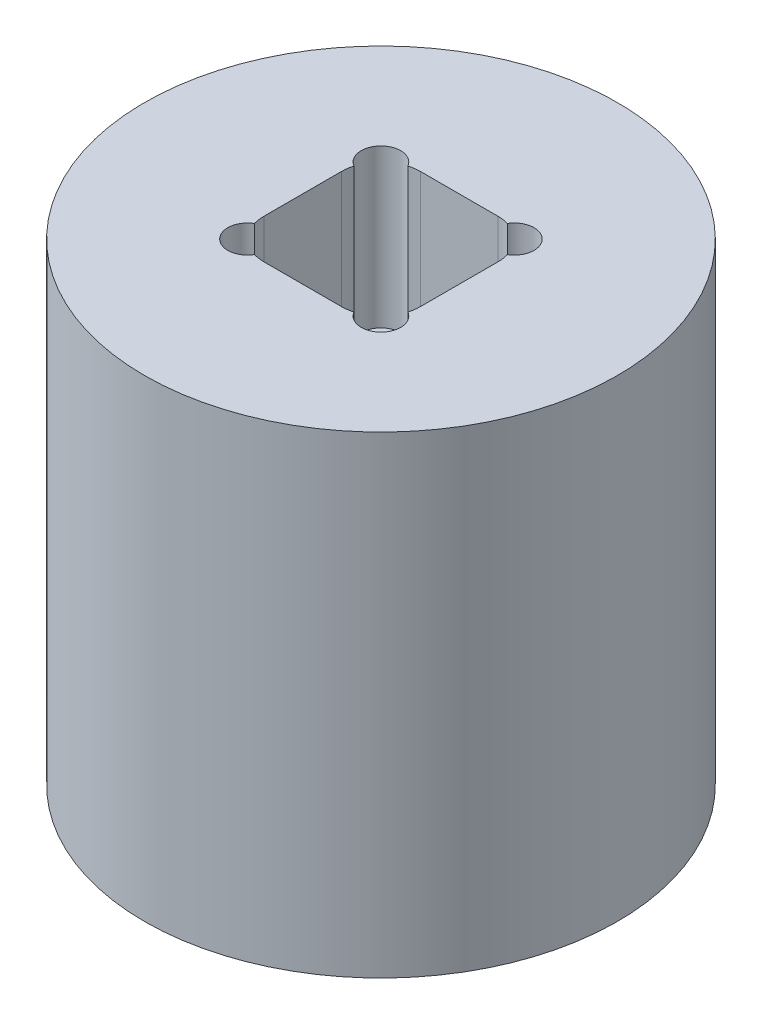
from build123d import *

# Parameters (mm, degrees)
SKETCH1_R           = 19.05
BOSS_EXTRUDE1_DEPTH = 19.05
SKETCH2_W           = 12.6111
SKETCH2_H           = 12.6111
CUT_EXTRUDE1_DEPTH  = 12.7
CUT_EXTRUDE2_DEPTH  = 19.05
FILLET1_R           = 3.175
CUT_EXTRUDE3_DEPTH  = 12.7


with BuildPart() as part:
    # Sketch1 → Boss-Extrude1 (new body, symmetric)
    with BuildSketch(Plane(origin=(0, 0, 0), x_dir=(1, 0, 0), z_dir=(0, 1, 0))):
        Circle(SKETCH1_R)
    extrude(amount=BOSS_EXTRUDE1_DEPTH, both=True)

    # Sketch2 → Cut-Extrude1 (cut)
    with BuildSketch(Plane(origin=(0, 19.05, 0), x_dir=(1, 0, 0), z_dir=(0, 1, 0))):
        Rectangle(SKETCH2_W, SKETCH2_H)
    extrude(amount=-CUT_EXTRUDE1_DEPTH, mode=Mode.SUBTRACT)

    # Sketch3 → Cut-Extrude2 (cut)
    with BuildSketch(Plane.XZ.offset(19.05)):
        with BuildLine():
            Line((9.12495, 12.29995), (-9.12495, 12.29995))
            ThreePointArc((-9.12495, 12.29995), (-11.37001403, 11.37001403), (-12.29995, 9.12495))
            Line((-12.29995, 9.12495), (-12.29995, -9.12495))
            ThreePointArc((-12.29995, -9.12495), (-11.37001403, -11.37001403), (-9.12495, -12.29995))
            Line((-9.12495, -12.29995), (9.12495, -12.29995))
            ThreePointArc((9.12495, -12.29995), (11.37001403, -11.37001403), (12.29995, -9.12495))
            Line((12.29995, -9.12495), (12.29995, 9.12495))
            ThreePointArc((12.29995, 9.12495), (11.37001403, 11.37001403), (9.12495, 12.29995))
        make_face()
    extrude(amount=-CUT_EXTRUDE2_DEPTH, mode=Mode.SUBTRACT)

    # Fillet1
    fillet1_edges = [part.edges().sort_by_distance(p)[0] for p in [
        (-6.30555, 12.7, 6.30555),
        (-6.30555, 12.7, -6.30555),
        (6.30555, 12.7, -6.30555),
        (6.30555, 12.7, 6.30555),
    ]]
    fillet(fillet1_edges, radius=FILLET1_R)

    # Sketch4 → Cut-Extrude3 (cut)
    with BuildSketch(Plane(origin=(0, 19.05, 0), x_dir=(1, 0, 0), z_dir=(0, 1, 0))):
        with BuildLine():
            ThreePointArc((4.008094076, 6.181867977), (4.253082015, 4.253082015), (6.181867977, 4.008094076))
            ThreePointArc((6.181867977, 4.008094076), (5.37561403, 5.37561403), (4.008094076, 6.181867977))
        make_face()
        with BuildLine():
            ThreePointArc((6.181867977, 4.008094076), (6.244651028, 4.047106994), (6.30555, 4.089000125))
            Line((6.30555, 4.089000125), (6.30555, 6.30555))
            Line((6.30555, 6.30555), (4.089000125, 6.30555))
            ThreePointArc((4.089000125, 6.30555), (4.047106994, 6.244651028), (4.008094076, 6.181867977))
            ThreePointArc((4.008094076, 6.181867977), (5.37561403, 5.37561403), (6.181867977, 4.008094076))
        make_face()
        with BuildLine():
            Line((6.30555, 6.30555), (6.30555, 4.089000125))
            ThreePointArc((6.30555, 4.089000125), (6.789196289, 4.653158877), (6.96311403, 5.37561403))
            ThreePointArc((6.96311403, 5.37561403), (5.864314693, 6.886020569), (4.089000125, 6.30555))
            Line((4.089000125, 6.30555), (6.30555, 6.30555))
        make_face()
        with BuildLine():
            ThreePointArc((-4.008094076, 6.181867977), (-5.37561403, 5.37561403), (-6.181867977, 4.008094076))
            ThreePointArc((-6.181867977, 4.008094076), (-4.588140821, 3.997193849), (-3.78811403, 5.37561403))
            ThreePointArc((-3.78811403, 5.37561403), (-3.844096127, 5.793476641), (-4.008094076, 6.181867977))
        make_face()
        with BuildLine():
            Line((-6.30555, 6.30555), (-6.30555, 4.089000125))
            ThreePointArc((-6.30555, 4.089000125), (-6.244651028, 4.047106994), (-6.181867977, 4.008094076))
            ThreePointArc((-6.181867977, 4.008094076), (-5.37561403, 5.37561403), (-4.008094076, 6.181867977))
            ThreePointArc((-4.008094076, 6.181867977), (-4.047106994, 6.244651028), (-4.089000125, 6.30555))
            Line((-4.089000125, 6.30555), (-6.30555, 6.30555))
        make_face()
        with BuildLine():
            ThreePointArc((-4.089000125, 6.30555), (-6.498146045, 6.498146045), (-6.30555, 4.089000125))
            Line((-6.30555, 4.089000125), (-6.30555, 6.30555))
            Line((-6.30555, 6.30555), (-4.089000125, 6.30555))
        make_face()
        with BuildLine():
            ThreePointArc((-6.30555, -4.089000125), (-6.498146045, -6.498146045), (-4.089000125, -6.30555))
            Line((-4.089000125, -6.30555), (-6.30555, -6.30555))
            Line((-6.30555, -6.30555), (-6.30555, -4.089000125))
        make_face()
        with BuildLine():
            Line((-6.30555, -6.30555), (-4.089000125, -6.30555))
            ThreePointArc((-4.089000125, -6.30555), (-4.047106994, -6.244651028), (-4.008094076, -6.181867977))
            ThreePointArc((-4.008094076, -6.181867977), (-5.37561403, -5.37561403), (-6.181867977, -4.008094076))
            ThreePointArc((-6.181867977, -4.008094076), (-6.244651028, -4.047106994), (-6.30555, -4.089000125))
            Line((-6.30555, -4.089000125), (-6.30555, -6.30555))
        make_face()
        with BuildLine():
            ThreePointArc((-6.181867977, -4.008094076), (-5.37561403, -5.37561403), (-4.008094076, -6.181867977))
            ThreePointArc((-4.008094076, -6.181867977), (-3.844096127, -5.793476641), (-3.78811403, -5.37561403))
            ThreePointArc((-3.78811403, -5.37561403), (-4.588140821, -3.997193849), (-6.181867977, -4.008094076))
        make_face()
        with BuildLine():
            ThreePointArc((6.181867977, -4.008094076), (4.253082015, -4.253082015), (4.008094076, -6.181867977))
            ThreePointArc((4.008094076, -6.181867977), (5.37561403, -5.37561403), (6.181867977, -4.008094076))
        make_face()
        with BuildLine():
            ThreePointArc((4.008094076, -6.181867977), (4.047106994, -6.244651028), (4.089000125, -6.30555))
            Line((4.089000125, -6.30555), (6.30555, -6.30555))
            Line((6.30555, -6.30555), (6.30555, -4.089000125))
            ThreePointArc((6.30555, -4.089000125), (6.244651028, -4.047106994), (6.181867977, -4.008094076))
            ThreePointArc((6.181867977, -4.008094076), (5.37561403, -5.37561403), (4.008094076, -6.181867977))
        make_face()
        with BuildLine():
            Line((6.30555, -6.30555), (4.089000125, -6.30555))
            ThreePointArc((4.089000125, -6.30555), (5.864314693, -6.886020569), (6.96311403, -5.37561403))
            ThreePointArc((6.96311403, -5.37561403), (6.789196289, -4.653158877), (6.30555, -4.089000125))
            Line((6.30555, -4.089000125), (6.30555, -6.30555))
        make_face()
    extrude(amount=-CUT_EXTRUDE3_DEPTH, mode=Mode.SUBTRACT)


solid = part.part
